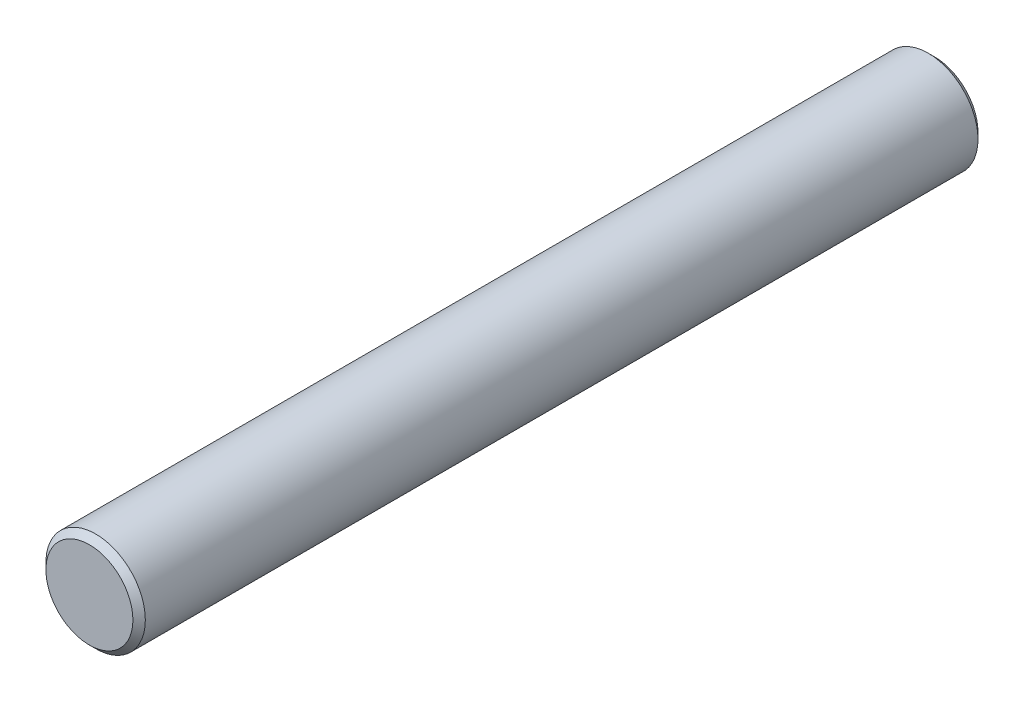
from build123d import *

# Parameters (mm, degrees)
SKETCH2_R           = 8
BOSS_EXTRUDE1_DEPTH = 68
CHAMFER1_SIZE       = 1


with BuildPart() as part:
    # Sketch2 → Boss-Extrude1 (new body, symmetric)
    with BuildSketch(Plane.XY):
        Circle(SKETCH2_R)
    extrude(amount=BOSS_EXTRUDE1_DEPTH, both=True)

    # Chamfer1
    chamfer1_edges = [part.edges().sort_by_distance(p)[0] for p in [
        (-8, 0, -68),
        (-8, 0, 68),
    ]]
    chamfer(chamfer1_edges, length=CHAMFER1_SIZE)


solid = part.part
